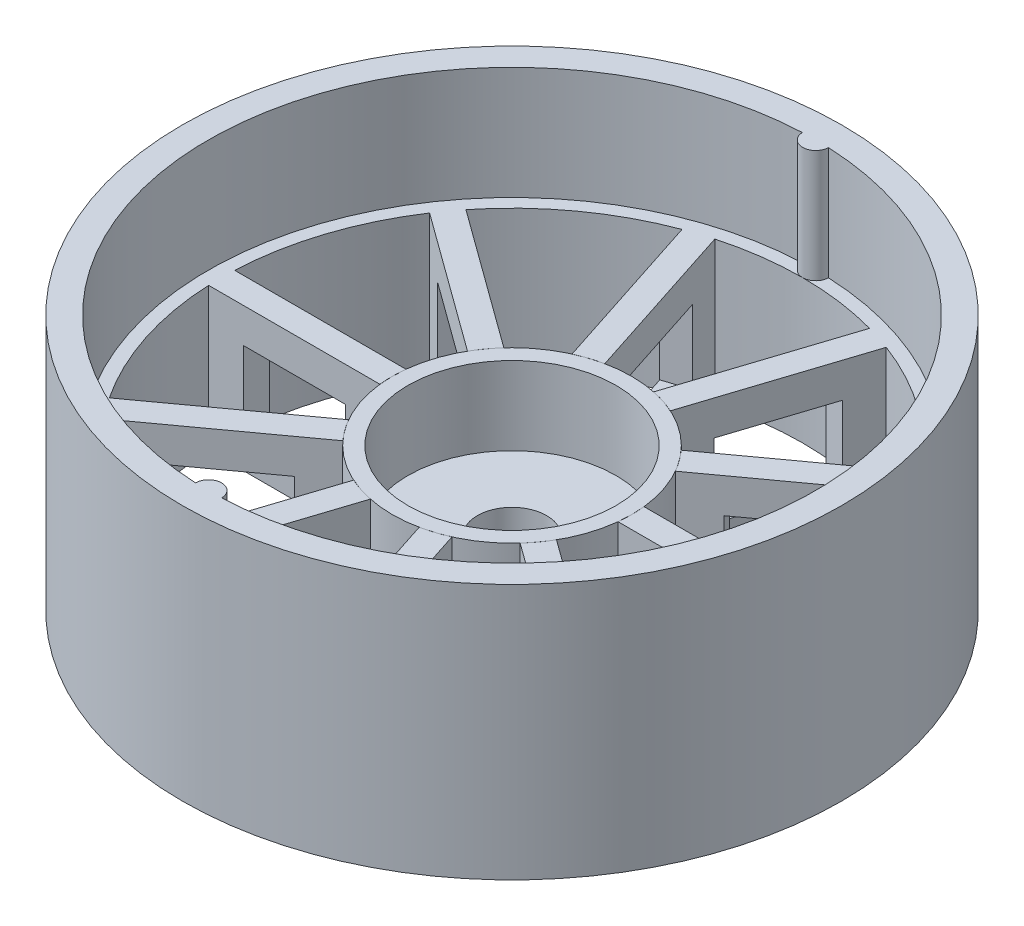
from build123d import *

# Parameters (mm, degrees)
SKETCH1_R           = 4
BOSS_EXTRUDE1_DEPTH = 16.5
SKETCH1_3_R         = 38
BOSS_EXTRUDE2_DEPTH = 29.5
CUT_EXTRUDE1_DEPTH  = 4.5
SKETCH3_R           = 12
CUT_EXTRUDE2_DEPTH  = 9
CUT_EXTRUDE4_DEPTH  = 57.216100896
BOSS_EXTRUDE6_DEPTH = 16.5
SKETCH6_W           = 11.748165023
SKETCH6_H           = 8.5
CUT_EXTRUDE5_DEPTH  = 3
CIRPATTERN1_COUNT   = 10
CIRPATTERN1_2_COUNT = 10


with BuildPart() as part:
    # Sketch1 → Boss-Extrude1 (new body)
    with BuildSketch(Plane(origin=(0, 0, 0), x_dir=(1, 0, 0), z_dir=(0, 1, 0))):
        with BuildLine():
            ThreePointArc((1.5, -34.96784237), (35, 0.000172372), (1.499655573, 34.967857143))
            ThreePointArc((1.499655573, 34.967857143), (-1.1078e-05, 33.5), (-1.499656047, 34.967879293))
            ThreePointArc((-1.499656047, 34.967879293), (-35.00002215, 0.000172134), (-1.5, -34.96786454))
            ThreePointArc((-1.5, -34.96786454), (-1.1085e-05, -33.46784237), (1.5, -34.96784237))
        make_face()
        with Locations(Location((0, 0, 0), (0, 0, 270))):
            Circle(SKETCH1_R, mode=Mode.SUBTRACT)
    extrude(amount=BOSS_EXTRUDE1_DEPTH)

    # Sketch1_3 → Boss-Extrude2 (add)
    with BuildSketch(Plane(origin=(0, 0, 0), x_dir=(1, 0, 0), z_dir=(0, 1, 0))):
        with Locations(Location((0, 0, 0), (0, 0, 270))):
            Circle(SKETCH1_3_R)
        with BuildLine():
            ThreePointArc((1.5, -34.96784237), (35, 0.000172372), (1.499655573, 34.967857143))
            ThreePointArc((1.499655573, 34.967857143), (-1.1078e-05, 33.5), (-1.499656047, 34.967879293))
            ThreePointArc((-1.499656047, 34.967879293), (-35.00002215, 0.000172134), (-1.5, -34.96786454))
            ThreePointArc((-1.5, -34.96786454), (-1.1085e-05, -33.46784237), (1.5, -34.96784237))
        make_face(mode=Mode.SUBTRACT)
    extrude(amount=BOSS_EXTRUDE2_DEPTH)

    # Sketch2 → Cut-Extrude1 (cut)
    with BuildSketch(Plane.XZ):
        Polygon((-3.637306696, 6.3), (-7.274613392, 0), (-3.637306696, -6.3), (3.637306696, -6.3), (7.274613392, 0), (3.637306696, 6.3), align=None)
    extrude(amount=-CUT_EXTRUDE1_DEPTH, mode=Mode.SUBTRACT)

    # Sketch3 → Cut-Extrude2 (cut)
    with BuildSketch(Plane(origin=(0, 16.5, 0), x_dir=(1, 0, 0), z_dir=(0, 1, 0))):
        with Locations(Location((0, 0, 0), (0, 0, 270))):
            Circle(SKETCH3_R)
    extrude(amount=-CUT_EXTRUDE2_DEPTH, mode=Mode.SUBTRACT)

    # Sketch5 → Cut-Extrude4 (cut, through all)
    with BuildSketch(Plane(origin=(0, 16.5, 0), x_dir=(1, 0, 0), z_dir=(0, 1, 0))):
        with BuildLine():
            ThreePointArc((13.718236038, -1.5), (-13.8, 0), (13.718236038, 1.5))
            Line((13.718236038, 1.5), (33.466401061, 1.5))
            ThreePointArc((33.466401061, 1.5), (-24.107867464, 23.260712077), (-0.30237508, -33.498635335))
            ThreePointArc((-0.30237508, -33.498635335), (0, -33.46784237), (0.30237508, -33.498635335))
            ThreePointArc((0.30237508, -33.498635335), (23.260712077, -24.107867464), (33.466401061, -1.5))
            Line((33.466401061, -1.5), (13.718236038, -1.5))
        make_face()
        with BuildLine():
            ThreePointArc((13.718236038, 1.5), (13.779543848, 0.751113398), (13.8, 0))
            Line((13.8, 0), (33.5, 0))
            ThreePointArc((33.5, 0), (33.491599212, 0.750188125), (33.466401061, 1.5))
            Line((33.466401061, 1.5), (13.718236038, 1.5))
        make_face()
        with BuildLine():
            Line((33.5, 0), (13.8, 0))
            ThreePointArc((13.8, 0), (13.779543848, -0.751113398), (13.718236038, -1.5))
            Line((13.718236038, -1.5), (33.466401061, -1.5))
            ThreePointArc((33.466401061, -1.5), (33.491599212, -0.750188125), (33.5, 0))
        make_face()
    extrude(amount=-CUT_EXTRUDE4_DEPTH, mode=Mode.SUBTRACT)


with BuildPart() as cut_extrude4_piece_1:
    # of the separate pieces the step leaves, piece 1, a body of its own (cut_extrude4_pieces)
    add(part.part.solids().sort_by_distance((1.499655573, 16.5, -34.967857143))[0])

    # Sketch5_3 → Boss-Extrude6 (add)
    with BuildSketch(Plane(origin=(0, 16.5, 0), x_dir=(1, 0, 0), z_dir=(0, 1, 0))):
        with BuildLine():
            Line((33.5, 0), (13.8, 0))
            ThreePointArc((13.8, 0), (13.779543848, -0.751113398), (13.718236038, -1.5))
            Line((13.718236038, -1.5), (33.466401061, -1.5))
            ThreePointArc((33.466401061, -1.5), (33.491599212, -0.750188125), (33.5, 0))
        make_face()
        with BuildLine():
            ThreePointArc((13.718236038, 1.5), (13.779543848, 0.751113398), (13.8, 0))
            Line((13.8, 0), (33.5, 0))
            ThreePointArc((33.5, 0), (33.491599212, 0.750188125), (33.466401061, 1.5))
            Line((33.466401061, 1.5), (13.718236038, 1.5))
        make_face()
    boss_extrude6 = extrude(amount=-BOSS_EXTRUDE6_DEPTH)

    # Sketch6 → Cut-Extrude5 (cut)
    with BuildSketch(Plane(origin=(-0.880879479, 0, -1.5), x_dir=(-1, 0, 0), z_dir=(0, 0, -1))):
        with Locations((-24.473198029, 8.25)):
            Rectangle(SKETCH6_W, SKETCH6_H)
    cut_extrude5 = extrude(amount=-CUT_EXTRUDE5_DEPTH, mode=Mode.SUBTRACT)

    # CirPattern1: Boss-Extrude6 ×10 about axis
    cirpattern1_axis = Axis((0, 0, 0), (0, 1, 0))
    for i in range(1, CIRPATTERN1_COUNT):
        add(boss_extrude6.rotate(cirpattern1_axis, i * 360 / CIRPATTERN1_COUNT))

    # CirPattern1 2: Cut-Extrude5 ×10 about axis
    cirpattern1_2_axis = Axis((0, 0, 0), (0, 1, 0))
    for i in range(1, CIRPATTERN1_2_COUNT):
        add(cut_extrude5.rotate(cirpattern1_2_axis, i * 360 / CIRPATTERN1_2_COUNT), mode=Mode.SUBTRACT)


with BuildPart() as cut_extrude4_piece_2:
    # of the separate pieces the step leaves, piece 2, a body of its own (cut_extrude4_pieces)
    add(part.part.solids().sort_by_distance((0, 4.5, 4))[0])


solid = Compound([cut_extrude4_piece_1.part, cut_extrude4_piece_2.part])
